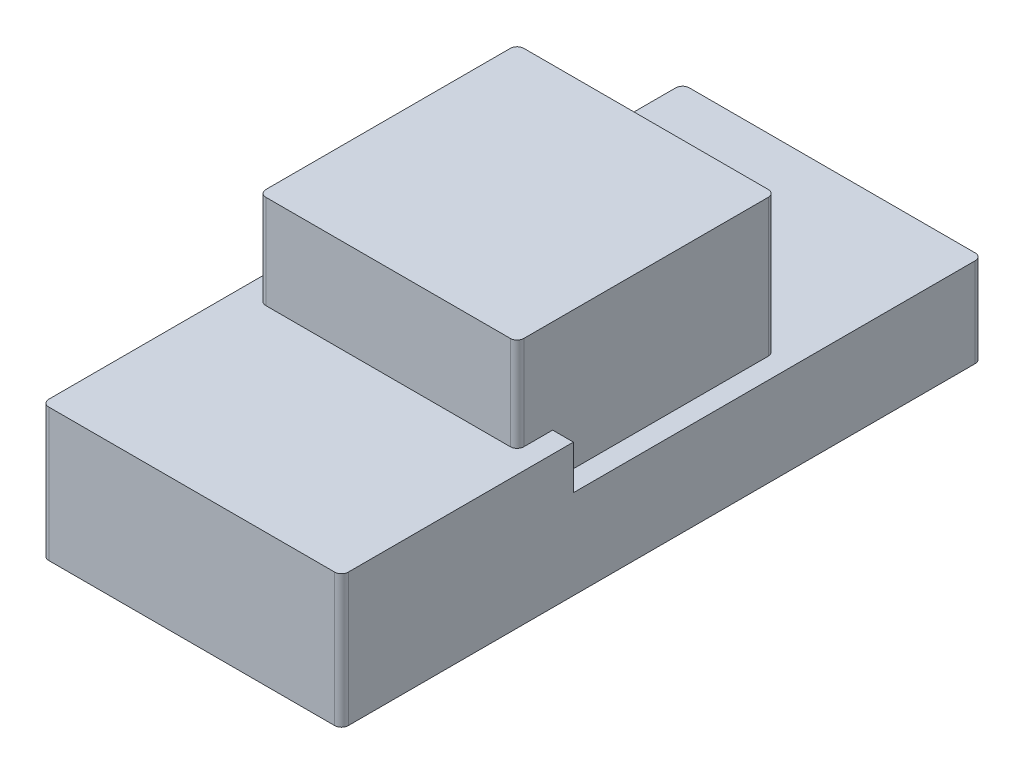
from build123d import *

# Parameters (mm, degrees)
SKETCH1_W           = 44.23
SKETCH1_H           = 94.6
BOSS_EXTRUDE1_DEPTH = 13.17
SKETCH2_W           = 38.1
SKETCH2_H           = 38.1
BOSS_EXTRUDE2_DEPTH = 20.33
FILLET1_R           = 1
BOSS_EXTRUDE3_DEPTH = 6.47


with BuildPart() as part:
    # Sketch1 → Boss-Extrude1 (new body)
    with BuildSketch(Plane(origin=(0, 0, 0), x_dir=(1, 0, 0), z_dir=(0, 1, 0))):
        Rectangle(SKETCH1_W, SKETCH1_H)
    extrude(amount=BOSS_EXTRUDE1_DEPTH)

    # Sketch2 → Boss-Extrude2 (add)
    with BuildSketch(Plane(origin=(0, 13.17, 0), x_dir=(1, 0, 0), z_dir=(0, 1, 0))):
        with Locations((0, 0.75)):
            Rectangle(SKETCH2_W, SKETCH2_H)
    extrude(amount=BOSS_EXTRUDE2_DEPTH)

    # Fillet1
    fillet1_edges = [part.edges().sort_by_distance(p)[0] for p in [
        (-19.05, 23.335, -19.8),
        (-19.05, 23.335, 18.3),
        (19.05, 23.335, 18.3),
        (19.05, 23.335, -19.8),
        (-22.115, 6.585, -47.3),
        (22.115, 6.585, -47.3),
        (22.115, 6.585, 47.3),
        (-22.115, 6.585, 47.3),
    ]]
    fillet(fillet1_edges, radius=FILLET1_R)

    # Sketch3 → Boss-Extrude3 (add)
    with BuildSketch(Plane(origin=(0, 13.17, 0), x_dir=(1, 0, 0), z_dir=(0, 1, 0))):
        with BuildLine():
            Line((-19.05, -13.043519039), (-22.115, -13.043519039))
            Line((-22.115, -13.043519039), (-22.115, -46.3))
            ThreePointArc((-22.115, -46.3), (-22.038879533, -46.682683432), (-21.822106781, -47.007106781))
            ThreePointArc((-21.822106781, -47.007106781), (-21.497683432, -47.223879533), (-21.115, -47.3))
            Line((-21.115, -47.3), (21.115, -47.3))
            ThreePointArc((21.115, -47.3), (21.497683432, -47.223879533), (21.822106781, -47.007106781))
            ThreePointArc((21.822106781, -47.007106781), (22.038879533, -46.682683432), (22.115, -46.3))
            Line((22.115, -46.3), (22.115, -17.3))
            Line((22.115, -17.3), (22.115, -13.043519039))
            Line((22.115, -13.043519039), (19.05, -13.043519039))
            Line((19.05, -13.043519039), (19.05, -17.3))
            ThreePointArc((19.05, -17.3), (18.973879533, -17.682683432), (18.757106781, -18.007106781))
            ThreePointArc((18.757106781, -18.007106781), (18.432683432, -18.223879533), (18.05, -18.3))
            Line((18.05, -18.3), (1.214814512, -18.3))
            Line((1.214814512, -18.3), (-18.05, -18.3))
            ThreePointArc((-18.05, -18.3), (-18.432683432, -18.223879533), (-18.757106781, -18.007106781))
            ThreePointArc((-18.757106781, -18.007106781), (-18.973879533, -17.682683432), (-19.05, -17.3))
            Line((-19.05, -17.3), (-19.05, -13.043519039))
        make_face()
    extrude(amount=BOSS_EXTRUDE3_DEPTH)


solid = part.part
